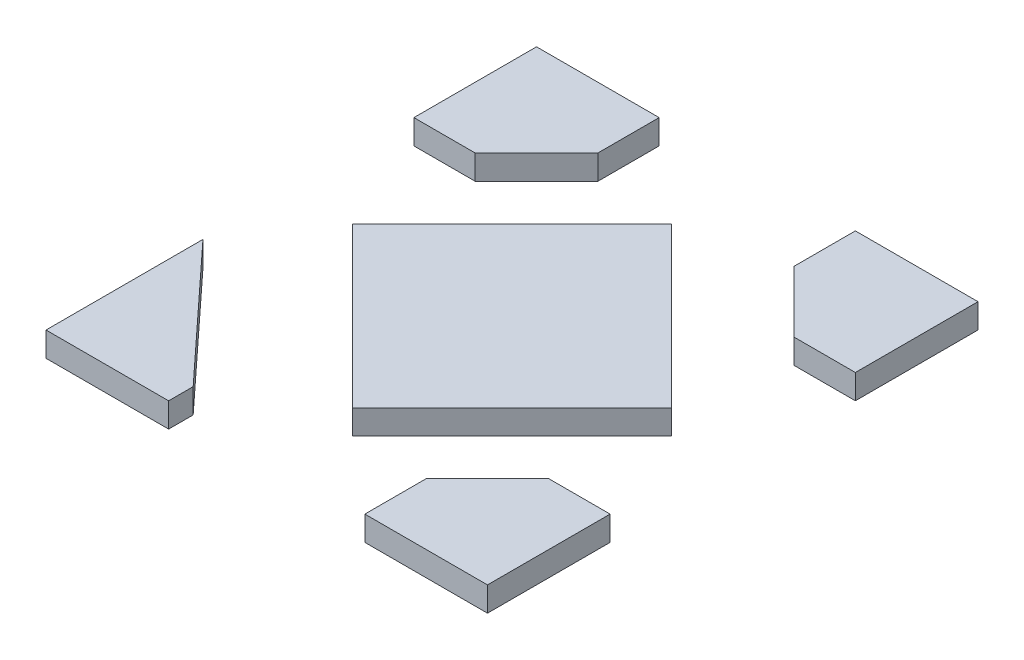
from build123d import *

# Parameters (mm, degrees)
SALIENTE_EXTRUIR1_DEPTH = 0.05
SALIENTE_EXTRUIR2_DEPTH = 0.05
MATRIZC5_COUNT          = 2
SALIENTE_EXTRUIR3_DEPTH = 0.05


with BuildPart() as part:
    # Croquis1 → Saliente-Extruir1 (new body)
    with BuildSketch(Plane.XZ):
        Polygon((0, -0.325), (0.325, 0), (0, 0.325), (-0.325, 0), align=None)
    extrude(amount=SALIENTE_EXTRUIR1_DEPTH)


with BuildPart() as body_2:
    # Croquis2 → Saliente-Extruir2 (new body)
    with BuildSketch(Plane.XZ):
        Polygon((0.2, 0.5), (0.45, 0.5), (0.45, 0.250000001), (0.325, 0.250000001), (0.2, 0.375000001), align=None)
    extrude(amount=SALIENTE_EXTRUIR2_DEPTH)


with BuildPart() as matrizc5_1:
    # MatrizC5: pattern copy
    add(body_2.part.rotate(Axis((0, 0, 0), (0, 1, 0)), 1 * 360 / MATRIZC5_COUNT))


with BuildPart() as body_4:
    # Simetría1: mirrored copy
    add(body_2.part.mirror(Plane.XY))


with BuildPart() as body_5:
    # Croquis3 → Saliente-Extruir3 (new body)
    with BuildSketch(Plane.XZ):
        Polygon((-0.45, 0.5), (-0.2, 0.5), (-0.2, 0.45), (-0.45, 0.18), align=None)
    extrude(amount=SALIENTE_EXTRUIR3_DEPTH)


solid = Compound([part.part, body_2.part, matrizc5_1.part, body_4.part, body_5.part])
